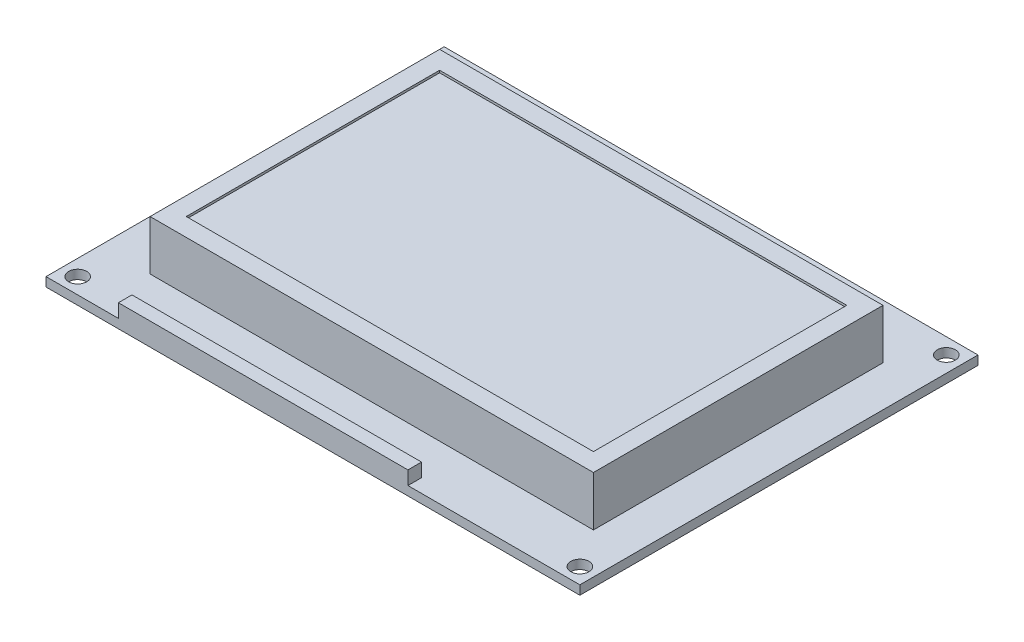
from build123d import *

# Parameters (mm, degrees)
SKETCH1_W           = 93.6625
SKETCH1_H           = 69.85
SKETCH1_R           = 1.5875
BOSS_EXTRUDE1_DEPTH = 1.5875
SKETCH2_W           = 77.7875
SKETCH2_H           = 50.8
BOSS_EXTRUDE2_DEPTH = 8.73125
SKETCH3_W           = 50.8
SKETCH3_H           = 2.38125
BOSS_EXTRUDE3_DEPTH = 2.38125
SKETCH4_W           = 71.4375
SKETCH4_H           = 44.45
CUT_EXTRUDE1_DEPTH  = 0.396875


with BuildPart() as part:
    # Sketch1 → Boss-Extrude1 (new body)
    with BuildSketch(Plane(origin=(0, 0, 0), x_dir=(1, 0, 0), z_dir=(0, 1, 0))):
        with Locations((46.83125, 34.925)):
            Rectangle(SKETCH1_W, SKETCH1_H)
        with Locations((2.778125, 67.071875)):
            Circle(SKETCH1_R, mode=Mode.SUBTRACT)
        with Locations((90.884375, 67.071875)):
            Circle(SKETCH1_R, mode=Mode.SUBTRACT)
        with Locations((2.778125, 2.778125)):
            Circle(SKETCH1_R, mode=Mode.SUBTRACT)
        with Locations((90.884375, 2.778125)):
            Circle(SKETCH1_R, mode=Mode.SUBTRACT)
    extrude(amount=BOSS_EXTRUDE1_DEPTH)

    # Sketch2 → Boss-Extrude2 (add)
    with BuildSketch(Plane(origin=(0, 1.5875, 0), x_dir=(1, 0, 0), z_dir=(0, 1, 0))):
        with Locations((47.625, 34.925)):
            Rectangle(SKETCH2_W, SKETCH2_H)
    extrude(amount=BOSS_EXTRUDE2_DEPTH)

    # Sketch3 → Boss-Extrude3 (add)
    with BuildSketch(Plane(origin=(0, 1.5875, 0), x_dir=(1, 0, 0), z_dir=(0, 1, 0))):
        with Locations((38.1, 1.190625)):
            Rectangle(SKETCH3_W, SKETCH3_H)
    extrude(amount=BOSS_EXTRUDE3_DEPTH)

    # Sketch4 → Cut-Extrude1 (cut)
    with BuildSketch(Plane(origin=(0, 10.31875, 0), x_dir=(1, 0, 0), z_dir=(0, 1, 0))):
        with Locations((47.625, 34.925)):
            Rectangle(SKETCH4_W, SKETCH4_H)
    extrude(amount=-CUT_EXTRUDE1_DEPTH, mode=Mode.SUBTRACT)


solid = part.part
